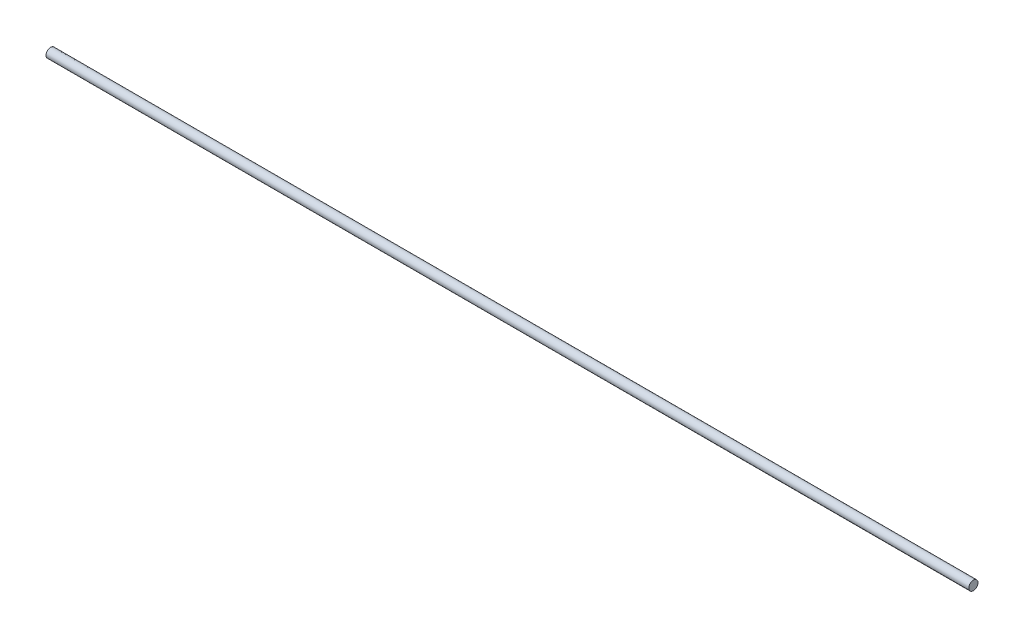
from build123d import *

# Parameters (mm, degrees)
SKETCH1_R           = 4
BOSS_EXTRUDE1_DEPTH = 800


with BuildPart() as part:
    # Sketch1 → Boss-Extrude1 (new body)
    with BuildSketch(Plane(origin=(0, 0, 0), x_dir=(0, 0, -1), z_dir=(1, 0, 0))):
        Circle(SKETCH1_R)
    extrude(amount=BOSS_EXTRUDE1_DEPTH)


solid = part.part
